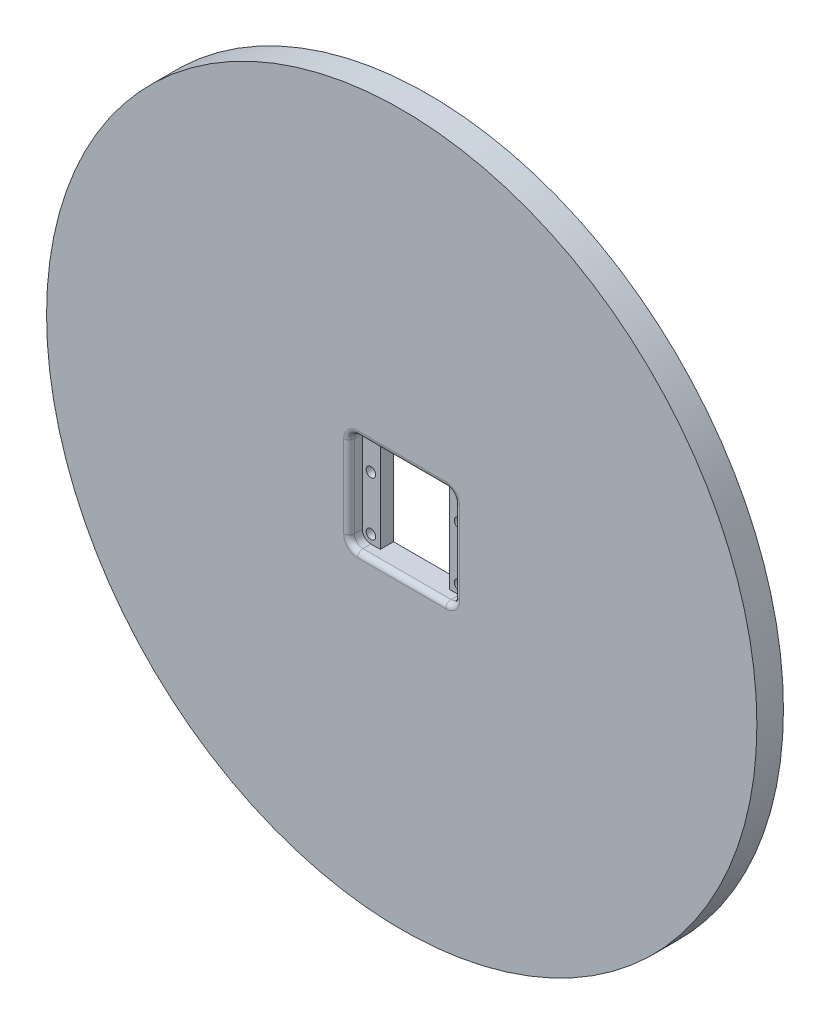
from build123d import *

# Parameters (mm, degrees)
SKETCH1_R           = 84.93125
BOSS_EXTRUDE1_DEPTH = 6.35
CUT_EXTRUDE2_DEPTH  = 3.175
SKETCH4_R           = 1.143
SKETCH4_W           = 16.6116
SKETCH4_H           = 23.7998
CUT_EXTRUDE3_DEPTH  = 3.175
FILLET1_R           = 1.27


with BuildPart() as part:
    # Sketch1 → Boss-Extrude1 (new body)
    with BuildSketch(Plane.XY):
        Circle(SKETCH1_R)
    extrude(amount=BOSS_EXTRUDE1_DEPTH)

    # Sketch2 → Cut-Extrude2 (cut)
    with BuildSketch(Plane.XY.offset(6.35)):
        with BuildLine():
            Line((10.541, 11.8999), (-10.541, 11.8999))
            ThreePointArc((-10.541, 11.8999), (-11.995801492, 11.297301492), (-12.5984, 9.8425))
            Line((-12.5984, 9.8425), (-12.5984, -9.8425))
            ThreePointArc((-12.5984, -9.8425), (-11.995801492, -11.297301492), (-10.541, -11.8999))
            Line((-10.541, -11.8999), (10.541, -11.8999))
            ThreePointArc((10.541, -11.8999), (11.995801492, -11.297301492), (12.5984, -9.8425))
            Line((12.5984, -9.8425), (12.5984, 9.8425))
            ThreePointArc((12.5984, 9.8425), (11.995801492, 11.297301492), (10.541, 11.8999))
        make_face()
    extrude(amount=-CUT_EXTRUDE2_DEPTH, mode=Mode.SUBTRACT)

    # Sketch4 → Cut-Extrude3 (cut)
    with BuildSketch(Plane.XY.offset(3.175)):
        with Locations((10.541, -9.8425)):
            Circle(SKETCH4_R)
        with Locations((-10.541, -9.8425)):
            Circle(SKETCH4_R)
        with Locations((10.541, 2.9845)):
            Circle(SKETCH4_R)
        with Locations((-10.541, 2.9845)):
            Circle(SKETCH4_R)
        Rectangle(SKETCH4_W, SKETCH4_H)
    extrude(amount=-CUT_EXTRUDE3_DEPTH, mode=Mode.SUBTRACT)

    # Fillet1
    fillet1_edges = [part.edges().sort_by_distance(p)[0] for p in [
        (-12.5984, 0, 6.35),
        (11.995801492, -11.297301492, 6.35),
        (12.5984, 0, 6.35),
        (11.995801492, 11.297301492, 6.35),
        (-11.995801492, -11.297301492, 6.35),
        (0, -11.8999, 6.35),
        (0, 11.8999, 6.35),
        (-11.995801492, 11.297301492, 6.35),
    ]]
    fillet(fillet1_edges, radius=FILLET1_R)


solid = part.part
